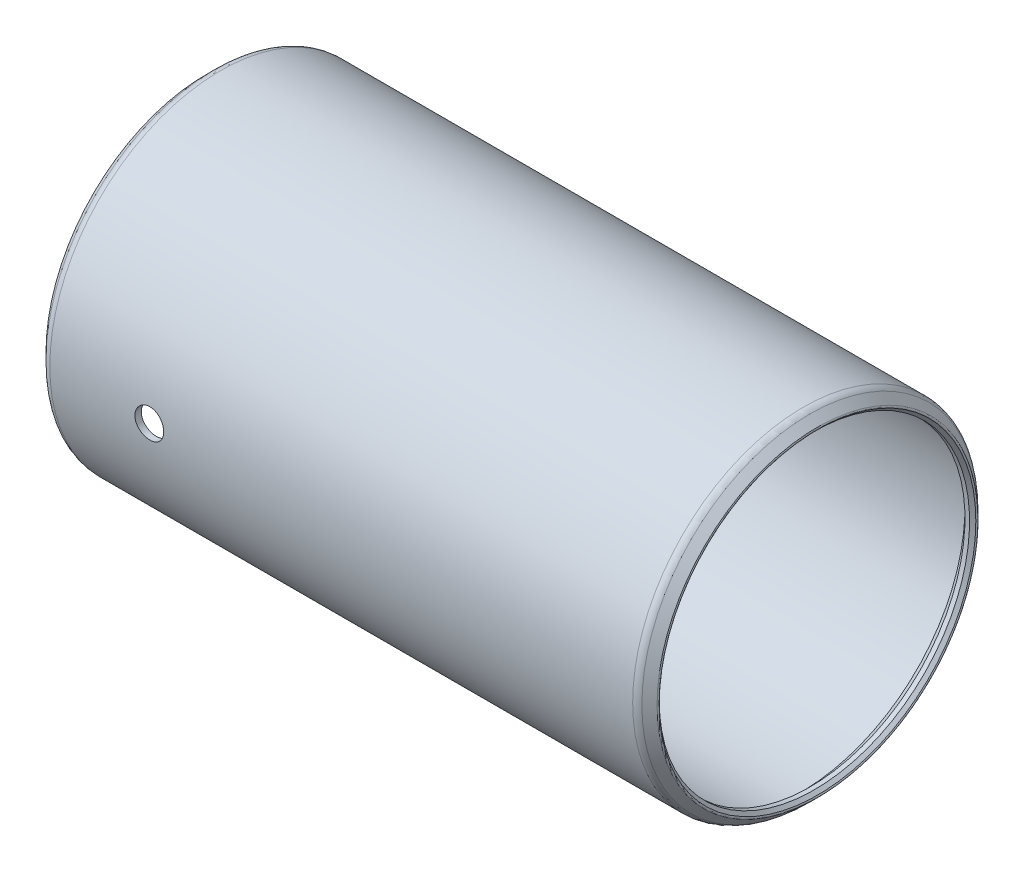
from build123d import *

# Parameters (mm, degrees)
SKETCH2_R          = 1.1938
CUT_EXTRUDE1_DEPTH = 14.1351


with BuildPart() as part:
    # Sketch1 → Revolve1 (revolve)
    with BuildSketch(Plane.XY):
        with BuildLine():
            Line((-0.639512806, 13.104562806), (-0.381, 12.84605))
            Line((-0.381, 12.84605), (0, 12.84605))
            Line((0, 12.84605), (0.762, 13.60805))
            Line((0.762, 13.60805), (48.5394, 13.60805))
            Line((48.5394, 13.60805), (49.3014, 12.84605))
            Line((49.3014, 12.84605), (49.6824, 12.84605))
            Line((49.6824, 12.84605), (49.940912806, 13.104562806))
            ThreePointArc((49.940912806, 13.104562806), (49.978110245, 13.194365367), (49.940912806, 13.284167928))
            Line((49.940912806, 13.284167928), (49.313165367, 13.911915367))
            ThreePointArc((49.313165367, 13.911915367), (49.065954775, 14.077096204), (48.77435, 14.1351))
            Line((48.77435, 14.1351), (0.52705, 14.1351))
            ThreePointArc((0.52705, 14.1351), (0.235445225, 14.077096204), (-0.011765367, 13.911915367))
            Line((-0.011765367, 13.911915367), (-0.639512806, 13.284167928))
            ThreePointArc((-0.639512806, 13.284167928), (-0.676710245, 13.194365367), (-0.639512806, 13.104562806))
        make_face()
    revolve(axis=Axis((49.3014, 0, 0), (-1, 0, 0)))

    # Sketch2 → Cut-Extrude1 (cut)
    with BuildSketch(Plane.XY):
        with Locations((8.763, 0)):
            Circle(SKETCH2_R)
    extrude(amount=CUT_EXTRUDE1_DEPTH, mode=Mode.SUBTRACT)


solid = part.part
